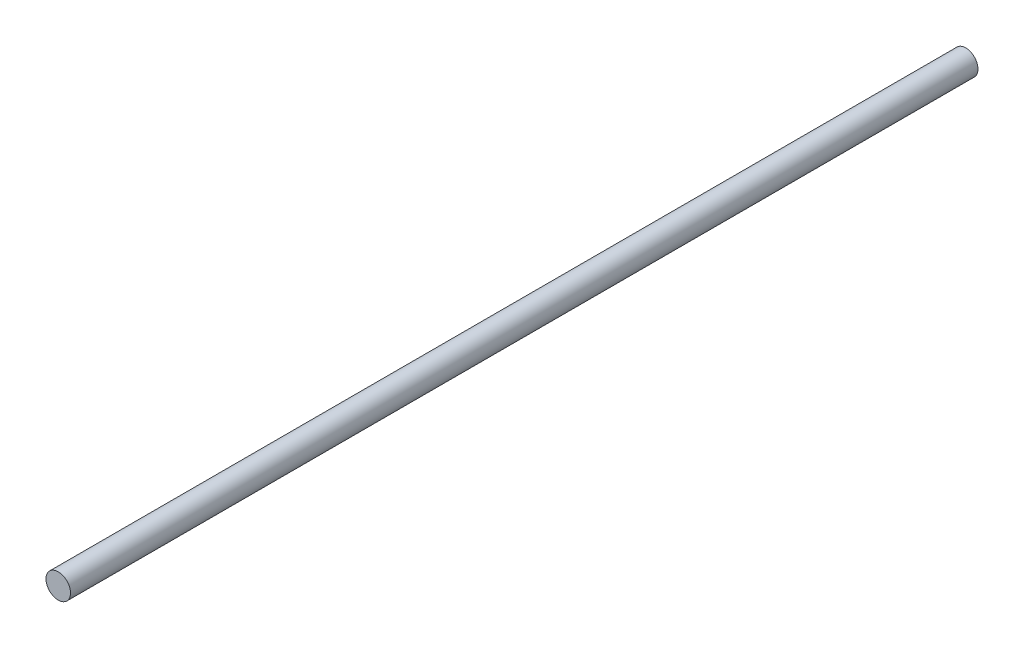
from build123d import *

# Parameters (mm, degrees)
SKETCH1_R           = 2.06121
BOSS_EXTRUDE1_DEPTH = 152.4


with BuildPart() as part:
    # Sketch1 → Boss-Extrude1 (new body)
    with BuildSketch(Plane.XY):
        Circle(SKETCH1_R)
    extrude(amount=BOSS_EXTRUDE1_DEPTH)


solid = part.part
